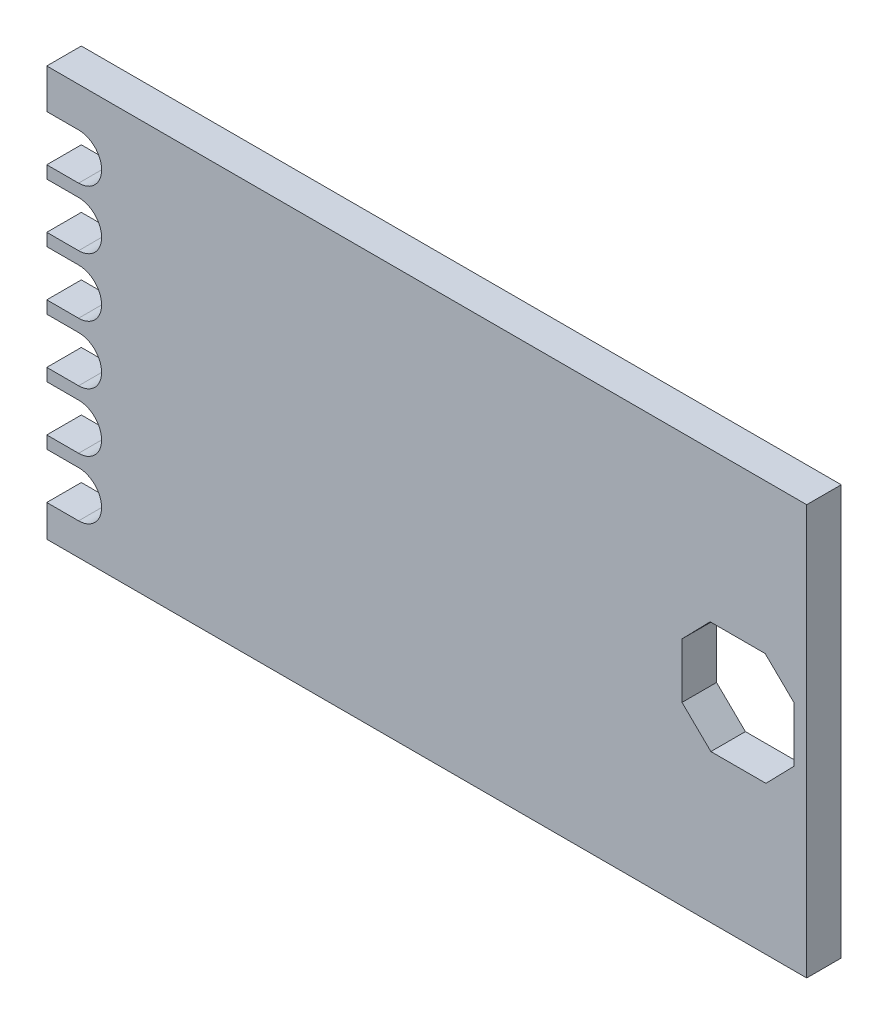
from build123d import *

# Parameters (mm, degrees)
SKETCH1_W           = 33
SKETCH1_H           = 17.8
MAIN_BODY_DEPTH     = 1.5
PIN_HOLE_DEPTH      = 1.5
PIN_HOLE_DEPTH_BACK = 10
CUT_EXTRUDE3_DEPTH  = 10


with BuildPart() as part:
    # Sketch1 → Main Body (new body)
    with BuildSketch(Plane.XY):
        with Locations((16.5, 8.9)):
            Rectangle(SKETCH1_W, SKETCH1_H)
    extrude(amount=MAIN_BODY_DEPTH)

    # Sketch7 → Pin Hole (cut, two sides)
    with BuildSketch(Plane(origin=(0, 0, 1.5), x_dir=(-1, 0, 0), z_dir=(0, 0, -1))) as pin_hole_sk:
        with BuildLine():
            Line((0, 16.084169392), (-1.381760133, 16.084169392))
            ThreePointArc((-1.381760133, 16.084169392), (-2.381760133, 15.084169392), (-1.381760133, 14.084169392))
            Line((-1.381760133, 14.084169392), (0, 14.084169392))
            Line((0, 14.084169392), (0, 16.084169392))
        make_face()
        with BuildLine():
            Line((0, 11.544169392), (0, 13.544169392))
            Line((0, 13.544169392), (-1.381760133, 13.544169392))
            ThreePointArc((-1.381760133, 13.544169392), (-2.381760133, 12.544169392), (-1.381760133, 11.544169392))
            Line((-1.381760133, 11.544169392), (0, 11.544169392))
        make_face()
        with BuildLine():
            Line((0, 9.004169392), (0, 11.004169392))
            Line((0, 11.004169392), (-1.381760133, 11.004169392))
            ThreePointArc((-1.381760133, 11.004169392), (-2.381760133, 10.004169392), (-1.381760133, 9.004169392))
            Line((-1.381760133, 9.004169392), (0, 9.004169392))
        make_face()
        with BuildLine():
            Line((0, 6.464169392), (0, 8.464169392))
            Line((0, 8.464169392), (-1.381760133, 8.464169392))
            ThreePointArc((-1.381760133, 8.464169392), (-2.381760133, 7.464169392), (-1.381760133, 6.464169392))
            Line((-1.381760133, 6.464169392), (0, 6.464169392))
        make_face()
        with BuildLine():
            Line((-1.381760133, 3.924169392), (0, 3.924169392))
            Line((0, 3.924169392), (0, 5.924169392))
            Line((0, 5.924169392), (-1.381760133, 5.924169392))
            ThreePointArc((-1.381760133, 5.924169392), (-2.381760133, 4.924169392), (-1.381760133, 3.924169392))
        make_face()
        with BuildLine():
            Line((-1.381760133, 1.384169392), (0, 1.384169392))
            Line((0, 1.384169392), (0, 3.384169392))
            Line((0, 3.384169392), (-1.381760133, 3.384169392))
            ThreePointArc((-1.381760133, 3.384169392), (-2.381760133, 2.384169392), (-1.381760133, 1.384169392))
        make_face()
    extrude(amount=PIN_HOLE_DEPTH, mode=Mode.SUBTRACT)
    extrude(pin_hole_sk.sketch, amount=-PIN_HOLE_DEPTH_BACK, mode=Mode.SUBTRACT)

    # Sketch10 → Cut-Extrude3 (cut)
    with BuildSketch(Plane(origin=(0, 0, 1.5), x_dir=(-1, 0, 0), z_dir=(0, 0, -1))):
        Polygon((-32.45, 7.689172953), (-32.45, 10.078883994), (-31.196454748, 11.3), (-28.806743708, 11.3), (-27.585627701, 10.046454748), (-27.585627701, 7.656743708), (-28.839172953, 6.435627701), (-31.228883994, 6.435627701), align=None)
    extrude(amount=CUT_EXTRUDE3_DEPTH, mode=Mode.SUBTRACT)


solid = part.part
